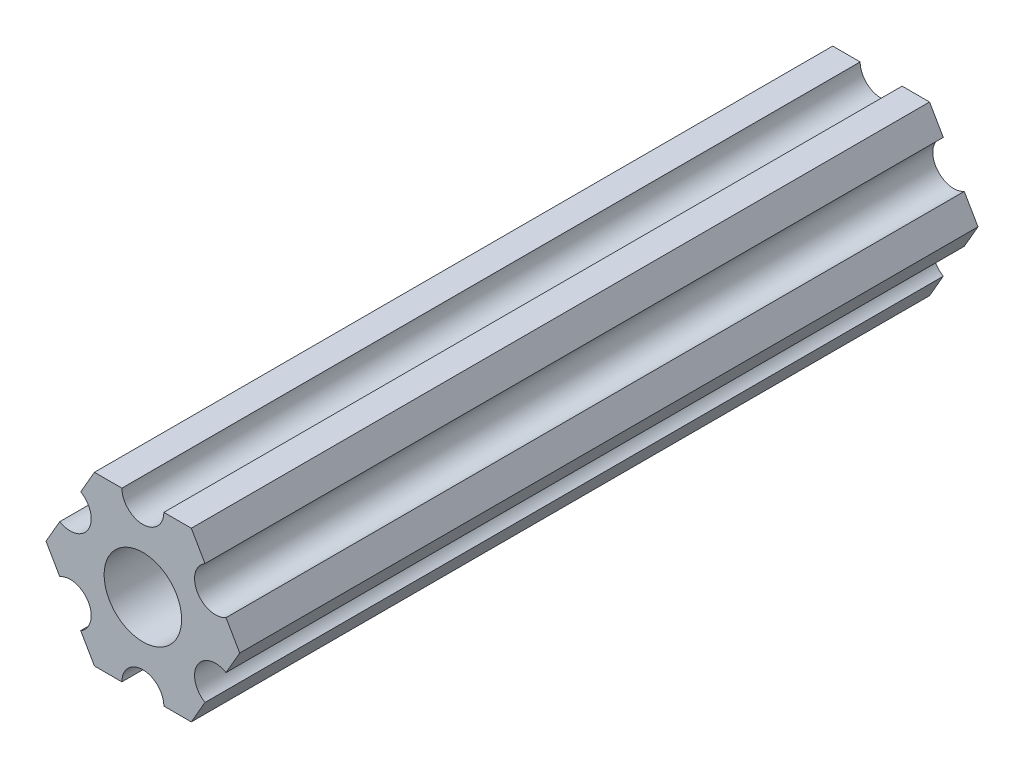
from build123d import *

# Parameters (mm, degrees)
SKETCH1_R           = 2.9337
BOSS_EXTRUDE1_DEPTH = 55.88


with BuildPart() as part:
    # Sketch1 → Boss-Extrude1 (new body)
    with BuildSketch(Plane.XY):
        with BuildLine():
            Line((-4.70551159, -4.549815043), (-3.666174521, -6.349999904))
            Line((-3.666174521, -6.349999904), (-1.587501154, -6.349999904))
            ThreePointArc((-1.587501154, -6.349999904), (-3.85e-07, -4.762499134), (1.587501154, -6.349999904))
            Line((1.587501154, -6.349999904), (3.666173825, -6.349999904))
            Line((3.666173825, -6.349999904), (4.705510929, -4.549815232))
            ThreePointArc((4.705510929, -4.549815232), (4.124445601, -2.381249904), (6.293010929, -1.800184575))
            Line((6.293010929, -1.800184575), (7.332348034, 9.6e-08))
            Line((7.332348034, 9.6e-08), (6.293011178, 1.800184715))
            ThreePointArc((6.293011178, 1.800184715), (4.124445902, 2.381250241), (4.705511428, 4.549815516))
            Line((4.705511428, 4.549815516), (3.666174521, 6.350000222))
            Line((3.666174521, 6.350000222), (1.587498846, 6.350000222))
            ThreePointArc((1.587498846, 6.350000222), (3.85e-07, 4.762501761), (-1.587498846, 6.350000222))
            Line((-1.587498846, 6.350000222), (-3.666173825, 6.350000222))
            Line((-3.666173825, 6.350000222), (-4.705511038, 4.549815614))
            ThreePointArc((-4.705511038, 4.549815614), (-4.124445841, 2.38125025), (-6.293011205, 1.800185053))
            Line((-6.293011205, 1.800185053), (-7.332348419, 4.44e-07))
            Line((-7.332348419, 4.44e-07), (-6.293011423, -1.80018429))
            ThreePointArc((-6.293011423, -1.80018429), (-4.12444613, -2.38124975), (-4.70551159, -4.549815043))
        make_face()
        Circle(SKETCH1_R, mode=Mode.SUBTRACT)
    extrude(amount=-BOSS_EXTRUDE1_DEPTH)


solid = part.part
